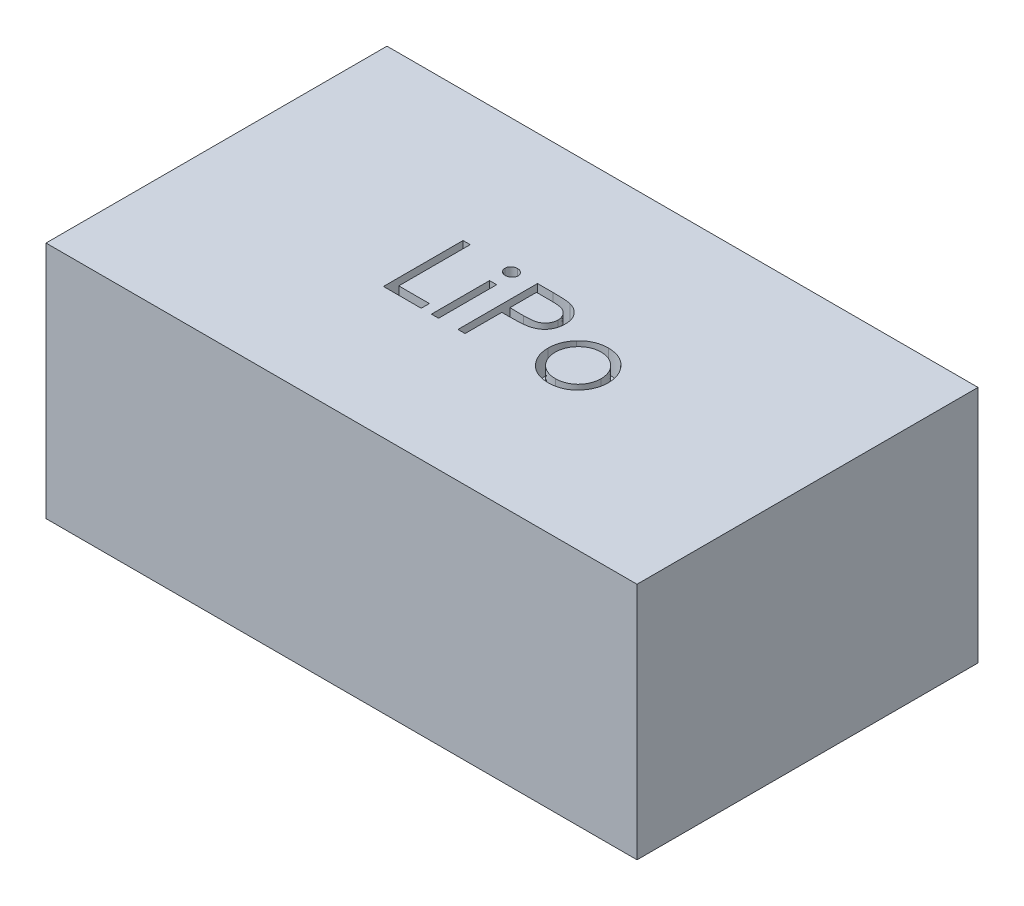
from build123d import *

# Parameters (mm, degrees)
SKETCH1_W           = 52
SKETCH1_H           = 30
BOSS_EXTRUDE1_DEPTH = 21
SKETCH2_W           = 0.628205128
SKETCH2_H           = 5.115384616
CUT_EXTRUDE1_DEPTH  = 2


with BuildPart() as part:
    # Sketch1 → Boss-Extrude1 (new body)
    with BuildSketch(Plane(origin=(0, 0, 0), x_dir=(1, 0, 0), z_dir=(0, 1, 0))):
        Rectangle(SKETCH1_W, SKETCH1_H)
    extrude(amount=BOSS_EXTRUDE1_DEPTH)

    # Sketch2 → Cut-Extrude1 (cut)
    with BuildSketch(Plane(origin=(0, 21, 0), x_dir=(1, 0, 0), z_dir=(0, 1, 0))):
        Polygon((-7.844024458, 3.53539681), (-7.21581933, 3.53539681), (-7.21581933, -2.746654472), (-4.523511638, -2.746654472), (-4.523511638, -3.46460319), (-7.844024458, -3.46460319), align=None)
        with BuildLine():
            add(Edge.make_bspline(
                [(-3.314777663, 3.804627579), (-3.275795032, 3.802819275), (-3.199459552, 3.799278267), (-3.089073017, 3.768955312), (-2.988558993, 3.717555942), (-2.899403527, 3.64859658), (-2.822899754, 3.567497693), (-2.769338333, 3.472975756), (-2.734913541, 3.370858479), (-2.73075643, 3.2996283), (-2.728639843, 3.263361554)],
                knots=[0, 0, 0, 0, 0.000116799, 0.000228716, 0.000340342, 0.000453368, 0.000565521, 0.000672313, 0.000776966, 0.00088552, 0.00088552, 0.00088552, 0.00088552], degree=3))
            add(Edge.make_bspline(
                [(-2.728639843, 3.263361554), (-2.730804163, 3.228036247), (-2.735082766, 3.158202297), (-2.769311743, 3.057855353), (-2.823356219, 2.964646786), (-2.89935447, 2.883705366), (-2.988571992, 2.814784126), (-3.089069564, 2.763374648), (-3.199460461, 2.733054373), (-3.275795339, 2.729512996), (-3.314777663, 2.727704503)],
                knots=[0, 0, 0, 0, 0.000105765, 0.000209085, 0.000314663, 0.000426817, 0.000539843, 0.000651469, 0.000763385, 0.000880185, 0.000880185, 0.000880185, 0.000880185], degree=3))
            add(Edge.make_bspline(
                [(-3.314777663, 2.727704503), (-3.353314214, 2.729443943), (-3.428320574, 2.732829537), (-3.537054259, 2.763969572), (-3.636711238, 2.814801718), (-3.726040583, 2.883254088), (-3.800500969, 2.965143883), (-3.85469762, 3.057798471), (-3.888847544, 3.15821678), (-3.893136801, 3.228041112), (-3.89530651, 3.263361554)],
                knots=[0, 0, 0, 0, 0.000115402, 0.000224615, 0.000336241, 0.000449268, 0.000560479, 0.000666058, 0.000769377, 0.000875142, 0.000875142, 0.000875142, 0.000875142], degree=3))
            add(Edge.make_bspline(
                [(-3.89530651, 3.263361554), (-3.893184336, 3.299623253), (-3.889016254, 3.370843518), (-3.854672022, 3.473033584), (-3.800952406, 3.566996588), (-3.725991279, 3.649047587), (-3.636724359, 3.717538456), (-3.537050868, 3.768360419), (-3.42832147, 3.799503098), (-3.353314518, 3.802888326), (-3.314777663, 3.804627579)],
                knots=[0, 0, 0, 0, 0.000108554, 0.000213207, 0.000319998, 0.00043121, 0.000544236, 0.000655862, 0.000765075, 0.000880477, 0.000880477, 0.000880477, 0.000880477], degree=3))
        make_face()
        with Locations((-3.311973176, -0.906910882)):
            Rectangle(SKETCH2_W, SKETCH2_H)
        with BuildLine():
            Line((-1.292742407, 3.53539681), (0.080054067, 3.53539681))
            add(Edge.make_bspline(
                [(0.080054067, 3.53539681), (0.17447588, 3.535293018), (0.355392265, 3.535094147), (0.614822377, 3.529064655), (0.85044184, 3.521011271), (1.061742602, 3.509847485), (1.249374798, 3.496654304), (1.412489397, 3.478150225), (1.55236851, 3.458829634), (1.636181409, 3.439186821), (1.674405029, 3.430228541)],
                knots=[0, 0, 0, 0, 0.000283257, 0.000542732, 0.000778459, 0.000990495, 0.00117752, 0.001342592, 0.001482999, 0.00160072, 0.00160072, 0.00160072, 0.00160072], degree=3))
            add(Edge.make_bspline(
                [(1.674405029, 3.430228541), (1.722792096, 3.416984641), (1.818426051, 3.390808918), (1.956228137, 3.338381471), (2.087335828, 3.276217141), (2.212198945, 3.205369261), (2.329283111, 3.122798133), (2.440335193, 3.031850897), (2.544375154, 2.93042776), (2.640817937, 2.81966628), (2.729387533, 2.70142586), (2.805646898, 2.573941401), (2.869501352, 2.439358794), (2.924267895, 2.297771652), (2.963684804, 2.147991005), (2.993378603, 1.99105758), (3.012225859, 1.826988199), (3.014030982, 1.714868464), (3.014949901, 1.657792644)],
                knots=[0, 0, 0, 0, 0.000150433, 0.000297321, 0.000441588, 0.000585426, 0.000727413, 0.000870867, 0.001015645, 0.001162727, 0.001311087, 0.001458262, 0.001607534, 0.001757541, 0.001912994, 0.002071404, 0.002236476, 0.002407642, 0.002407642, 0.002407642, 0.002407642], degree=3))
            add(Edge.make_bspline(
                [(3.014949901, 1.657792644), (3.014107051, 1.60023709), (3.012457959, 1.487625762), (2.992665389, 1.322880186), (2.966005005, 1.165443405), (2.925010901, 1.015664505), (2.871319555, 0.874432964), (2.808335449, 0.7395905), (2.732368388, 0.613431156), (2.645078729, 0.495496921), (2.54797554, 0.385677096), (2.441469664, 0.284767507), (2.325991079, 0.19335883), (2.201906783, 0.111246143), (2.068007085, 0.040333584), (1.926322778, -0.023181026), (1.775622345, -0.076523147), (1.671337317, -0.10458327), (1.618315285, -0.118849985)],
                knots=[0, 0, 0, 0, 0.000172567, 0.000337639, 0.000497175, 0.000651275, 0.000802594, 0.000949996, 0.001097172, 0.00124357, 0.001389599, 0.0015364, 0.001683127, 0.001830916, 0.001982111, 0.002137159, 0.00229638, 0.002461065, 0.002461065, 0.002461065, 0.002461065], degree=3))
            add(Edge.make_bspline(
                [(1.618315285, -0.118849985), (1.574460617, -0.128175947), (1.478350563, -0.148614335), (1.320065118, -0.171431249), (1.135774346, -0.19090645), (0.925729787, -0.205508725), (0.690119977, -0.218009462), (0.428817462, -0.22794565), (0.141309308, -0.233405358), (-0.05923318, -0.233686943), (-0.163936317, -0.233833959)],
                knots=[0, 0, 0, 0, 0.000134477, 0.000294713, 0.000479453, 0.000690354, 0.000926269, 0.001187271, 0.001474786, 0.001788891, 0.001788891, 0.001788891, 0.001788891], degree=3))
            Line((-0.163936317, -0.233833959), (-0.664537279, -0.233833959))
            Line((-0.664537279, -0.233833959), (-0.664537279, -3.46460319))
            Line((-0.664537279, -3.46460319), (-1.292742407, -3.46460319))
            Line((-1.292742407, -3.46460319), (-1.292742407, 3.53539681))
        make_face()
        with BuildLine():
            Line((-0.664537279, 2.817448092), (-0.664537279, 0.484114759))
            Line((-0.664537279, 0.484114759), (0.561023619, 0.468690079))
            add(Edge.make_bspline(
                [(0.561023619, 0.468690079), (0.62086347, 0.468659152), (0.73638307, 0.468599448), (0.903255517, 0.476569895), (1.058074091, 0.48577096), (1.200363242, 0.499242807), (1.330187111, 0.518285322), (1.447762169, 0.537508798), (1.552176734, 0.565319523), (1.674375138, 0.602765661), (1.810541833, 0.666630893), (1.95867693, 0.759330673), (2.084218103, 0.877492089), (2.192854696, 1.010347752), (2.279066452, 1.158146011), (2.342178437, 1.316283884), (2.379260751, 1.483139583), (2.384233139, 1.597315861), (2.386744772, 1.654988156)],
                knots=[0, 0, 0, 0, 0.000179493, 0.000346507, 0.000501066, 0.00064478, 0.000775068, 0.00089472, 0.001001852, 0.001098972, 0.001277806, 0.001451282, 0.001620977, 0.001792452, 0.001964649, 0.00213208, 0.002301514, 0.002474451, 0.002474451, 0.002474451, 0.002474451], degree=3))
            add(Edge.make_bspline(
                [(2.386744772, 1.654988156), (2.384219479, 1.711265183), (2.37919951, 1.823136948), (2.341887783, 1.987094469), (2.279189156, 2.143565878), (2.192275966, 2.289512048), (2.086793707, 2.421889656), (1.96419502, 2.53688391), (1.824768498, 2.629327316), (1.695072036, 2.688993879), (1.579869664, 2.72542443), (1.479805744, 2.750914111), (1.366824395, 2.771265323), (1.240888836, 2.787744329), (1.102975168, 2.801851251), (0.951898538, 2.811423206), (0.788231252, 2.817026118), (0.67461011, 2.817304029), (0.615711119, 2.817448092)],
                knots=[0, 0, 0, 0, 0.000168742, 0.000335438, 0.000501567, 0.000672554, 0.00084315, 0.001007853, 0.001174696, 0.001342854, 0.001434205, 0.001536914, 0.001652427, 0.001778356, 0.001917884, 0.002068245, 0.002232403, 0.002409092, 0.002409092, 0.002409092, 0.002409092], degree=3))
            Line((0.615711119, 2.817448092), (-0.664537279, 2.817448092))
        make_face(mode=Mode.SUBTRACT)
        with BuildLine():
            add(Edge.make_bspline(
                [(6.742113362, 1.740525015), (6.838095908, 1.738481233), (7.026294223, 1.734473876), (7.301909995, 1.691643944), (7.565000267, 1.626149215), (7.816572651, 1.535606091), (8.053405242, 1.41424219), (8.27894773, 1.269423608), (8.492581748, 1.097858421), (8.620627806, 0.965142284), (8.685622978, 0.897776618)],
                knots=[0, 0, 0, 0, 0.000287737, 0.000564182, 0.000834557, 0.001100277, 0.00136429, 0.001631118, 0.001903331, 0.002183937, 0.002183937, 0.002183937, 0.002183937], degree=3))
            add(Edge.make_bspline(
                [(8.685622978, 0.897776618), (8.741586886, 0.833348646), (8.852431646, 0.705739562), (8.994563084, 0.498828336), (9.117006204, 0.284548135), (9.215132126, 0.060053481), (9.292502173, -0.172695861), (9.347433566, -0.414499883), (9.380107436, -0.664824577), (9.38451337, -0.834832254), (9.386744772, -0.920933318)],
                knots=[0, 0, 0, 0, 0.000255843, 0.000506735, 0.000751626, 0.000995234, 0.00124045, 0.001486391, 0.001738065, 0.001996322, 0.001996322, 0.001996322, 0.001996322], degree=3))
            add(Edge.make_bspline(
                [(9.386744772, -0.920933318), (9.384782098, -1.007533433), (9.380903761, -1.1786593), (9.344216528, -1.430698032), (9.287154357, -1.675087677), (9.20549068, -1.910805064), (9.100774462, -2.138570719), (8.972993087, -2.357389818), (8.821249852, -2.567694084), (8.649241859, -2.767697761), (8.459138107, -2.95203019), (8.25290581, -3.11268673), (8.034597742, -3.250329778), (7.801311036, -3.36120261), (7.555176062, -3.44862201), (7.295661926, -3.510022043), (7.023171785, -3.547145411), (6.837117343, -3.551912557), (6.742113362, -3.55434678)],
                knots=[0, 0, 0, 0, 0.000259658, 0.000513095, 0.000762403, 0.001011624, 0.00126009, 0.001513338, 0.001770565, 0.002037035, 0.002303804, 0.002563549, 0.002819949, 0.003076471, 0.003336809, 0.003602097, 0.003875174, 0.004160109, 0.004160109, 0.004160109, 0.004160109], degree=3))
            add(Edge.make_bspline(
                [(6.742113362, -3.55434678), (6.646643923, -3.551904387), (6.459662204, -3.547120838), (6.18621024, -3.510166273), (5.926231002, -3.448650308), (5.679773805, -3.360915322), (5.445484111, -3.250326235), (5.225911117, -3.113102855), (5.019511286, -2.951982545), (4.829367317, -2.767710671), (4.657370107, -2.567690758), (4.50562409, -2.357390681), (4.377843438, -2.138570494), (4.27312703, -1.910805124), (4.191463404, -1.675087661), (4.134401219, -1.430698036), (4.09771399, -1.178659299), (4.093835653, -1.007533433), (4.091872978, -0.920933318)],
                knots=[0, 0, 0, 0, 0.000286336, 0.000560803, 0.000826091, 0.001086429, 0.001344217, 0.001601806, 0.001861551, 0.00212832, 0.002394791, 0.002652017, 0.002905265, 0.003153731, 0.003402952, 0.00365226, 0.003905698, 0.004165355, 0.004165355, 0.004165355, 0.004165355], degree=3))
            add(Edge.make_bspline(
                [(4.091872978, -0.920933318), (4.094119598, -0.835300226), (4.098567521, -0.665761421), (4.131208539, -0.4159073), (4.185925652, -0.174512522), (4.263388445, 0.05733843), (4.362418827, 0.280849302), (4.483141403, 0.495658964), (4.626722668, 0.701634565), (4.737126571, 0.829078725), (4.792994772, 0.893569887)],
                knots=[0, 0, 0, 0, 0.000256856, 0.00050853, 0.000754471, 0.000998357, 0.001240681, 0.001486794, 0.001736535, 0.001992378, 0.001992378, 0.001992378, 0.001992378], degree=3))
            add(Edge.make_bspline(
                [(4.792994772, 0.893569887), (4.857891955, 0.961519766), (4.985523682, 1.095155158), (5.200221138, 1.266220206), (5.42520878, 1.414052354), (5.664658632, 1.533004785), (5.916024348, 1.62668182), (6.180462833, 1.691812851), (6.457013864, 1.734319561), (6.646133106, 1.738435916), (6.742113362, 1.740525015)],
                knots=[0, 0, 0, 0, 0.000281596, 0.000553808, 0.000821398, 0.001087917, 0.001354122, 0.001624497, 0.001903716, 0.002191452, 0.002191452, 0.002191452, 0.002191452], degree=3))
        make_face()
        with BuildLine():
            add(Edge.make_bspline(
                [(6.739308875, 1.112319887), (6.671433652, 1.110390704), (6.537435395, 1.106582139), (6.340196226, 1.077614329), (6.150315918, 1.031719321), (5.96743423, 0.966511209), (5.792167885, 0.882313411), (5.62434908, 0.77889669), (5.4634842, 0.657630777), (5.312720073, 0.518705434), (5.174355449, 0.366947445), (5.053399496, 0.205250727), (4.950549283, 0.036238035), (4.864868965, -0.140266387), (4.801054589, -0.326051215), (4.754708544, -0.519012478), (4.725768063, -0.719543311), (4.721995306, -0.855865347), (4.720078106, -0.925140049)],
                knots=[0, 0, 0, 0, 0.000203562, 0.000401869, 0.000596746, 0.000788792, 0.000983219, 0.001178981, 0.001379222, 0.001586646, 0.001793123, 0.001994486, 0.002191445, 0.002385872, 0.002581885, 0.002779487, 0.002980571, 0.003188335, 0.003188335, 0.003188335, 0.003188335], degree=3))
            add(Edge.make_bspline(
                [(4.720078106, -0.925140049), (4.723291753, -1.014644103), (4.729670242, -1.192292914), (4.781540715, -1.453915159), (4.868313275, -1.705078864), (4.985487834, -1.944311636), (5.132300271, -2.165656192), (5.305274405, -2.36299916), (5.502553805, -2.533370783), (5.721786806, -2.674732474), (5.958495442, -2.787051986), (6.209008084, -2.866649937), (6.470289472, -2.918393322), (6.648850934, -2.923536271), (6.739308875, -2.926141651)],
                knots=[0, 0, 0, 0, 0.000268357, 0.000532638, 0.000796487, 0.001063639, 0.001329655, 0.001590974, 0.001848472, 0.002109066, 0.002371256, 0.002632005, 0.002896022, 0.003167094, 0.003167094, 0.003167094, 0.003167094], degree=3))
            add(Edge.make_bspline(
                [(6.739308875, -2.926141651), (6.829761613, -2.923521091), (7.008312805, -2.918348177), (7.269231159, -2.866910538), (7.519059102, -2.786703216), (7.755521877, -2.674858796), (7.974655084, -2.532833967), (8.173353327, -2.363961213), (8.344850549, -2.16513351), (8.491517759, -1.944018452), (8.610611244, -1.705449748), (8.696977648, -1.453868804), (8.74897282, -1.19230472), (8.755334477, -1.014648058), (8.758539644, -0.925140049)],
                knots=[0, 0, 0, 0, 0.000271072, 0.000535089, 0.000794504, 0.001056694, 0.001317288, 0.001575849, 0.001836244, 0.002102261, 0.002370034, 0.002633883, 0.002898164, 0.003166521, 0.003166521, 0.003166521, 0.003166521], degree=3))
            add(Edge.make_bspline(
                [(8.758539644, -0.925140049), (8.756623104, -0.855864933), (8.752851646, -0.719542082), (8.723901717, -0.519017175), (8.677590638, -0.326033982), (8.613647403, -0.140329975), (8.528339376, 0.036695034), (8.42350579, 0.204754488), (8.303043739, 0.36750758), (8.163009497, 0.518214861), (8.012402741, 0.657684935), (7.851472665, 0.778943713), (7.683902708, 0.881858904), (7.509145542, 0.967231386), (7.326240407, 1.031126066), (7.136626149, 1.077879329), (6.940228529, 1.106459722), (6.806710442, 1.110354005), (6.739308875, 1.112319887)],
                knots=[0, 0, 0, 0, 0.000207764, 0.000408848, 0.00060645, 0.000802463, 0.00099689, 0.001194582, 0.001395944, 0.001603367, 0.00181079, 0.002011031, 0.002206794, 0.002399958, 0.002593325, 0.00278684, 0.002985147, 0.003187308, 0.003187308, 0.003187308, 0.003187308], degree=3))
        make_face(mode=Mode.SUBTRACT)
    extrude(amount=-CUT_EXTRUDE1_DEPTH, mode=Mode.SUBTRACT)


solid = part.part
